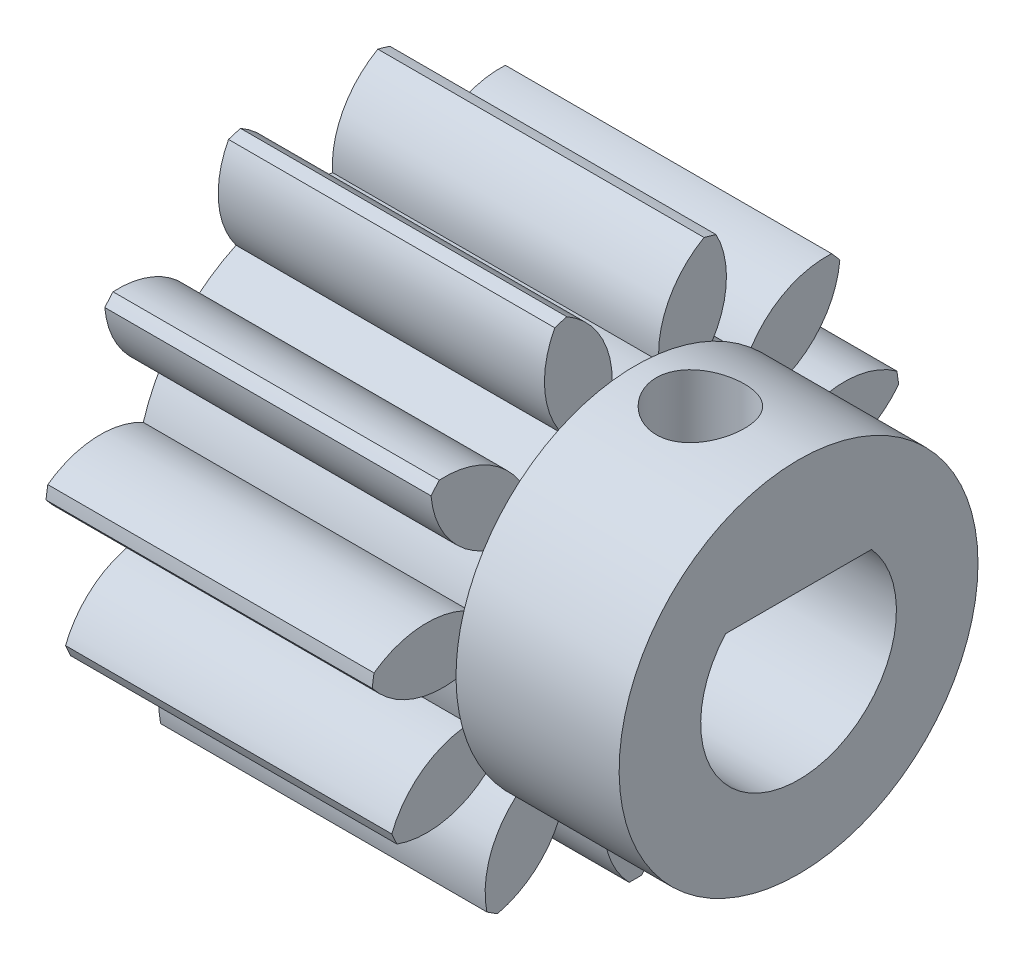
from build123d import *

# Parameters (mm, degrees)
BASPROSKE_W              = 10
BASPROSKE_H              = 8.125
TOOTHCUT_DEPTH           = 16.232572009
TEETHCUTS_COUNT          = 11
TEETHCUTS_ANGLE          = 327.272727273
BORSKE_R                 = 3
BORE_DEPTH               = 50.0000508
RESSALTO_EXTRUS_O1_DEPTH = 10
RESSALTO_EXTRUS_O2_DEPTH = 5
ESBO_O3_R                = 1.35
CORTE_EXTRUS_O1_DEPTH    = 10


with BuildPart() as part:
    # BasProSke → Base-Revolve (revolve)
    with BuildSketch(Plane(origin=(0, 0, 0), x_dir=(1, 0, 0), z_dir=(0, 1, 0)), mode=Mode.PRIVATE) as base_revolve_sk:
        with Locations((5, 4.0625)):
            Rectangle(BASPROSKE_W, BASPROSKE_H)
    revolve(base_revolve_sk.sketch.rotate(Axis((-10, 0, 0), (1, 0, 0)), 180), axis=Axis((-10, 0, 0), (1, 0, 0)))

    # TooCutSke → ToothCut (cut, through all)
    with BuildSketch(Plane(origin=(0, 0, 0), x_dir=(0, 0, -1), z_dir=(1, 0, 0))):
        with BuildLine():
            ThreePointArc((0.716661614, 5.262929639), (0, 5.3115), (-0.716661614, 5.262929639))
            ThreePointArc((-0.716661614, 5.262929639), (-1.045232485, 6.771828733), (-2.135233901, 7.865735589))
            ThreePointArc((-2.135233901, 7.865735589), (0, 8.1504), (2.135233901, 7.865735589))
            ThreePointArc((2.135233901, 7.865735589), (1.045232485, 6.771828733), (0.716661614, 5.262929639))
        make_face()
    toothcut = extrude(amount=TOOTHCUT_DEPTH, mode=Mode.SUBTRACT)

    # TeethCuts: ToothCut ×11 about axis
    teethcuts_axis = Axis((-10, 0, 0), (1, 0, 0))
    for i in range(1, TEETHCUTS_COUNT):
        add(toothcut.rotate(teethcuts_axis, i * TEETHCUTS_ANGLE / (TEETHCUTS_COUNT - 1)), mode=Mode.SUBTRACT)

    # BorSke → Bore (cut, symmetric)
    with BuildSketch(Plane(origin=(0, 0, 0), x_dir=(0, 0, -1), z_dir=(1, 0, 0))):
        with Locations(Location((0, 0, 0), (0, 0, 180))):
            Circle(BORSKE_R)
    extrude(amount=BORE_DEPTH, both=True, mode=Mode.SUBTRACT)

    # Esboço1 → Ressalto-extrusão1 (add)
    with BuildSketch(Plane.ZY):
        with BuildLine():
            Line((-2.236067977, 2), (0, 2))
            Line((0, 2), (2.236067977, 2))
            ThreePointArc((2.236067977, 2), (0, 3), (-2.236067977, 2))
        make_face()
    extrude(amount=-RESSALTO_EXTRUS_O1_DEPTH)

    # Esboço2 → Ressalto-extrusão2 (add)
    with BuildSketch(Plane(origin=(10, 0, 0), x_dir=(0, 0, -1), z_dir=(1, 0, 0))):
        with BuildLine():
            ThreePointArc((5.499508602, -0.073519622), (5.499877149, -0.036760632), (5.5, 0))
            ThreePointArc((5.5, 0), (5.438664747, 0.819100589), (5.256026991, 1.619932181))
            ThreePointArc((5.256026991, 1.619932181), (5.169790583, 1.578653269), (5.085041182, 1.534401651))
            ThreePointArc((5.085041182, 1.534401651), (4.831510343, 2.206476842), (4.489617195, 2.838198318))
            ThreePointArc((4.489617195, 2.838198318), (4.578559391, 2.873268994), (4.666228749, 2.911410184))
            ThreePointArc((4.666228749, 2.911410184), (4.156622659, 3.601734037), (3.545849816, 4.204396399))
            ThreePointArc((3.545849816, 4.204396399), (3.495620198, 4.123047446), (3.448248696, 4.040001631))
            ThreePointArc((3.448248696, 4.040001631), (2.871613702, 4.46831814), (2.242460468, 4.814914672))
            ThreePointArc((2.242460468, 4.814914672), (2.298322765, 4.892503784), (2.351454238, 4.971987828))
            ThreePointArc((2.351454238, 4.971987828), (1.549529063, 5.277211355), (0.709890379, 5.453994467))
            ThreePointArc((0.709890379, 5.453994467), (0.711615099, 5.358403192), (0.716661614, 5.262929639))
            ThreePointArc((0.716661614, 5.262929639), (0, 5.3115), (-0.716661614, 5.262929639))
            ThreePointArc((-0.716661614, 5.262929639), (-0.711615099, 5.358403192), (-0.709890379, 5.453994467))
            ThreePointArc((-0.709890379, 5.453994467), (-1.549529063, 5.277211355), (-2.351454238, 4.971987828))
            ThreePointArc((-2.351454238, 4.971987828), (-2.298322765, 4.892503784), (-2.242460468, 4.814914672))
            ThreePointArc((-2.242460468, 4.814914672), (-2.871613702, 4.46831814), (-3.448248696, 4.040001631))
            ThreePointArc((-3.448248696, 4.040001631), (-3.495620198, 4.123047446), (-3.545849816, 4.204396399))
            ThreePointArc((-3.545849816, 4.204396399), (-4.156622659, 3.601734037), (-4.666228749, 2.911410184))
            ThreePointArc((-4.666228749, 2.911410184), (-4.578559391, 2.873268994), (-4.489617195, 2.838198318))
            ThreePointArc((-4.489617195, 2.838198318), (-4.831510343, 2.206476842), (-5.085041182, 1.534401651))
            ThreePointArc((-5.085041182, 1.534401651), (-5.169790583, 1.578653269), (-5.256026991, 1.619932181))
            ThreePointArc((-5.256026991, 1.619932181), (-5.44401793, 0.782731611), (-5.499508602, -0.073519622))
            ThreePointArc((-5.499508602, -0.073519622), (-5.405135761, -0.0582084), (-5.311352185, -0.039625949))
            ThreePointArc((-5.311352185, -0.039625949), (-5.257436589, -0.755905263), (-5.107369022, -1.458360012))
            ThreePointArc((-5.107369022, -1.458360012), (-5.202588986, -1.466952167), (-5.297452733, -1.478849059))
            ThreePointArc((-5.297452733, -1.478849059), (-5.002975974, -2.284782572), (-4.586733332, -3.035107468))
            ThreePointArc((-4.586733332, -3.035107468), (-4.515619718, -2.971205038), (-4.446770385, -2.904869256))
            ThreePointArc((-4.446770385, -2.904869256), (-4.014163864, -3.478292788), (-3.508143284, -3.988102675))
            ThreePointArc((-3.508143284, -3.988102675), (-3.583602145, -4.046810655), (-3.656974663, -4.108106171))
            ThreePointArc((-3.656974663, -4.108106171), (-2.973524496, -4.626894431), (-2.217702637, -5.033070138))
            ThreePointArc((-2.217702637, -5.033070138), (-2.19242632, -4.940865071), (-2.170370406, -4.8478371))
            ThreePointArc((-2.170370406, -4.8478371), (-1.496422476, -5.096346929), (-0.795106841, -5.251650918))
            ThreePointArc((-0.795106841, -5.251650918), (-0.826846944, -5.341835354), (-0.855432976, -5.433068601))
            ThreePointArc((-0.855432976, -5.433068601), (0, -5.5), (0.855432976, -5.433068601))
            ThreePointArc((0.855432976, -5.433068601), (0.826846944, -5.341835354), (0.795106841, -5.251650918))
            ThreePointArc((0.795106841, -5.251650918), (1.496422476, -5.096346929), (2.170370406, -4.8478371))
            ThreePointArc((2.170370406, -4.8478371), (2.19242632, -4.940865071), (2.217702637, -5.033070138))
            ThreePointArc((2.217702637, -5.033070138), (2.973524496, -4.626894431), (3.656974663, -4.108106171))
            ThreePointArc((3.656974663, -4.108106171), (3.583602145, -4.046810655), (3.508143284, -3.988102675))
            ThreePointArc((3.508143284, -3.988102675), (4.014163864, -3.478292788), (4.446770385, -2.904869256))
            ThreePointArc((4.446770385, -2.904869256), (4.515619718, -2.971205038), (4.586733332, -3.035107468))
            ThreePointArc((4.586733332, -3.035107468), (5.002975974, -2.284782572), (5.297452733, -1.478849059))
            ThreePointArc((5.297452733, -1.478849059), (5.202588986, -1.466952167), (5.107369022, -1.458360012))
            ThreePointArc((5.107369022, -1.458360012), (5.257436589, -0.755905263), (5.311352185, -0.039625949))
            ThreePointArc((5.311352185, -0.039625949), (5.405135761, -0.0582084), (5.499508602, -0.073519622))
        make_face()
        with BuildLine():
            Line((-2.236067977, 2), (2.236067977, 2))
            ThreePointArc((2.236067977, 2), (0, -3), (-2.236067977, 2))
        make_face(mode=Mode.SUBTRACT)
        with BuildLine():
            ThreePointArc((3.448248696, 4.040001631), (3.495620198, 4.123047446), (3.545849816, 4.204396399))
            ThreePointArc((3.545849816, 4.204396399), (2.973524496, 4.626894431), (2.351454238, 4.971987828))
            ThreePointArc((2.351454238, 4.971987828), (2.298322765, 4.892503784), (2.242460468, 4.814914672))
            ThreePointArc((2.242460468, 4.814914672), (2.871613702, 4.46831814), (3.448248696, 4.040001631))
        make_face()
        with BuildLine():
            ThreePointArc((0.716661614, 5.262929639), (0.711615099, 5.358403192), (0.709890379, 5.453994467))
            ThreePointArc((0.709890379, 5.453994467), (0, 5.5), (-0.709890379, 5.453994467))
            ThreePointArc((-0.709890379, 5.453994467), (-0.711615099, 5.358403192), (-0.716661614, 5.262929639))
            ThreePointArc((-0.716661614, 5.262929639), (0, 5.3115), (0.716661614, 5.262929639))
        make_face()
        with BuildLine():
            ThreePointArc((-2.242460468, 4.814914672), (-2.298322765, 4.892503784), (-2.351454238, 4.971987828))
            ThreePointArc((-2.351454238, 4.971987828), (-2.973524496, 4.626894431), (-3.545849816, 4.204396399))
            ThreePointArc((-3.545849816, 4.204396399), (-3.495620198, 4.123047446), (-3.448248696, 4.040001631))
            ThreePointArc((-3.448248696, 4.040001631), (-2.871613702, 4.46831814), (-2.242460468, 4.814914672))
        make_face()
        with BuildLine():
            ThreePointArc((-4.489617195, 2.838198318), (-4.578559391, 2.873268994), (-4.666228749, 2.911410184))
            ThreePointArc((-4.666228749, 2.911410184), (-5.002975974, 2.284782572), (-5.256026991, 1.619932181))
            ThreePointArc((-5.256026991, 1.619932181), (-5.169790583, 1.578653269), (-5.085041182, 1.534401651))
            ThreePointArc((-5.085041182, 1.534401651), (-4.831510343, 2.206476842), (-4.489617195, 2.838198318))
        make_face()
        with BuildLine():
            ThreePointArc((-5.311352185, -0.039625949), (-5.405135761, -0.0582084), (-5.499508602, -0.073519622))
            ThreePointArc((-5.499508602, -0.073519622), (-5.44401793, -0.782731611), (-5.297452733, -1.478849059))
            ThreePointArc((-5.297452733, -1.478849059), (-5.202588986, -1.466952167), (-5.107369022, -1.458360012))
            ThreePointArc((-5.107369022, -1.458360012), (-5.257436589, -0.755905263), (-5.311352185, -0.039625949))
        make_face()
        with BuildLine():
            ThreePointArc((-4.586733332, -3.035107468), (-4.156622659, -3.601734037), (-3.656974663, -4.108106171))
            ThreePointArc((-3.656974663, -4.108106171), (-3.583602145, -4.046810655), (-3.508143284, -3.988102675))
            ThreePointArc((-3.508143284, -3.988102675), (-4.014163864, -3.478292788), (-4.446770385, -2.904869256))
            ThreePointArc((-4.446770385, -2.904869256), (-4.515619718, -2.971205038), (-4.586733332, -3.035107468))
        make_face()
        with BuildLine():
            ThreePointArc((-2.217702637, -5.033070138), (-1.549529063, -5.277211355), (-0.855432976, -5.433068601))
            ThreePointArc((-0.855432976, -5.433068601), (-0.826846944, -5.341835354), (-0.795106841, -5.251650918))
            ThreePointArc((-0.795106841, -5.251650918), (-1.496422476, -5.096346929), (-2.170370406, -4.8478371))
            ThreePointArc((-2.170370406, -4.8478371), (-2.19242632, -4.940865071), (-2.217702637, -5.033070138))
        make_face()
        with BuildLine():
            ThreePointArc((0.855432976, -5.433068601), (1.549529063, -5.277211355), (2.217702637, -5.033070138))
            ThreePointArc((2.217702637, -5.033070138), (2.19242632, -4.940865071), (2.170370406, -4.8478371))
            ThreePointArc((2.170370406, -4.8478371), (1.496422476, -5.096346929), (0.795106841, -5.251650918))
            ThreePointArc((0.795106841, -5.251650918), (0.826846944, -5.341835354), (0.855432976, -5.433068601))
        make_face()
        with BuildLine():
            ThreePointArc((3.656974663, -4.108106171), (4.156622659, -3.601734037), (4.586733332, -3.035107468))
            ThreePointArc((4.586733332, -3.035107468), (4.515619718, -2.971205038), (4.446770385, -2.904869256))
            ThreePointArc((4.446770385, -2.904869256), (4.014163864, -3.478292788), (3.508143284, -3.988102675))
            ThreePointArc((3.508143284, -3.988102675), (3.583602145, -4.046810655), (3.656974663, -4.108106171))
        make_face()
        with BuildLine():
            ThreePointArc((5.297452733, -1.478849059), (5.44401793, -0.782731611), (5.499508602, -0.073519622))
            ThreePointArc((5.499508602, -0.073519622), (5.405135761, -0.0582084), (5.311352185, -0.039625949))
            ThreePointArc((5.311352185, -0.039625949), (5.257436589, -0.755905263), (5.107369022, -1.458360012))
            ThreePointArc((5.107369022, -1.458360012), (5.202588986, -1.466952167), (5.297452733, -1.478849059))
        make_face()
        with BuildLine():
            ThreePointArc((5.085041182, 1.534401651), (5.169790583, 1.578653269), (5.256026991, 1.619932181))
            ThreePointArc((5.256026991, 1.619932181), (5.002975974, 2.284782572), (4.666228749, 2.911410184))
            ThreePointArc((4.666228749, 2.911410184), (4.578559391, 2.873268994), (4.489617195, 2.838198318))
            ThreePointArc((4.489617195, 2.838198318), (4.831510343, 2.206476842), (5.085041182, 1.534401651))
        make_face()
    extrude(amount=RESSALTO_EXTRUS_O2_DEPTH)

    # Esboço3 → Corte-extrusão1 (cut)
    with BuildSketch(Plane.XZ.offset(-2)):
        with Locations(Location((11.990687454, 0, 0), (0, 0, 270))):
            Circle(ESBO_O3_R)
    extrude(amount=-CORTE_EXTRUS_O1_DEPTH, mode=Mode.SUBTRACT)


solid = part.part
